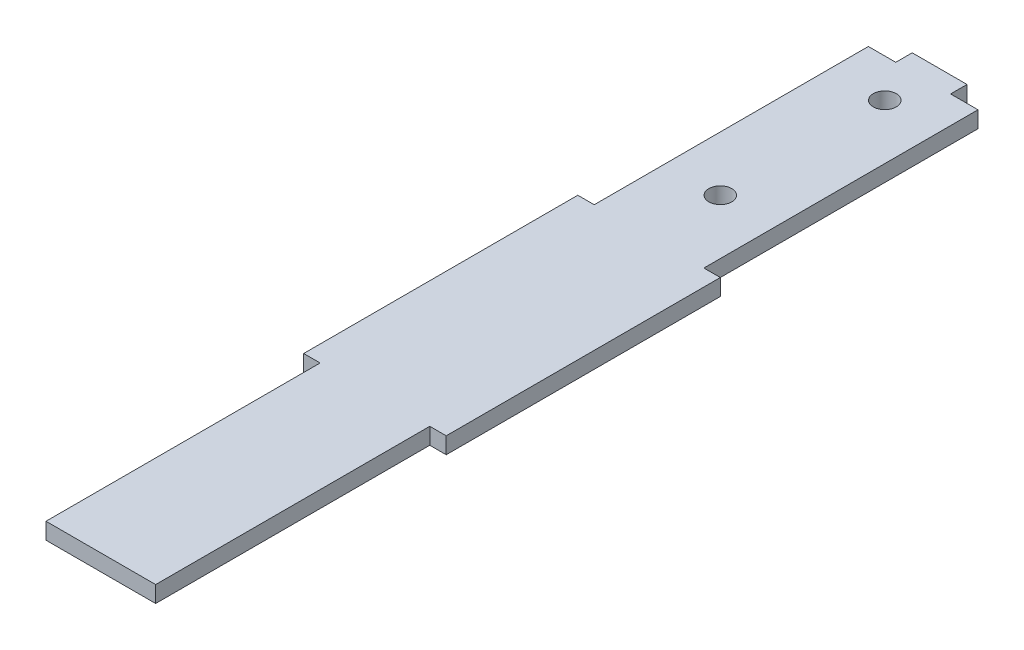
from build123d import *

# Parameters (mm, degrees)
BOSS_EXTRUDE1_DEPTH = 3
SKETCH2_R           = 2.1
CUT_EXTRUDE1_DEPTH  = 4


with BuildPart() as part:
    # Sketch1 → Boss-Extrude1 (new body)
    with BuildSketch(Plane(origin=(0, 0, 0), x_dir=(1, 0, 0), z_dir=(0, 1, 0))):
        Polygon((15, 0), (20, 0), (20, -50), (23, -50), (23, -100), (20, -100), (20, -150), (0, -150), (0, -100), (-3, -100), (-3, -50), (0, -50), (0, 0), (5, 0), (5, 3), (15, 3), align=None)
    extrude(amount=BOSS_EXTRUDE1_DEPTH)

    # Sketch2 → Cut-Extrude1 (cut, through all)
    with BuildSketch(Plane(origin=(0, 3, 0), x_dir=(1, 0, 0), z_dir=(0, 1, 0))):
        with Locations((10, -7)):
            Circle(SKETCH2_R)
        with Locations((10, -37)):
            Circle(SKETCH2_R)
    extrude(amount=-CUT_EXTRUDE1_DEPTH, mode=Mode.SUBTRACT)


solid = part.part
